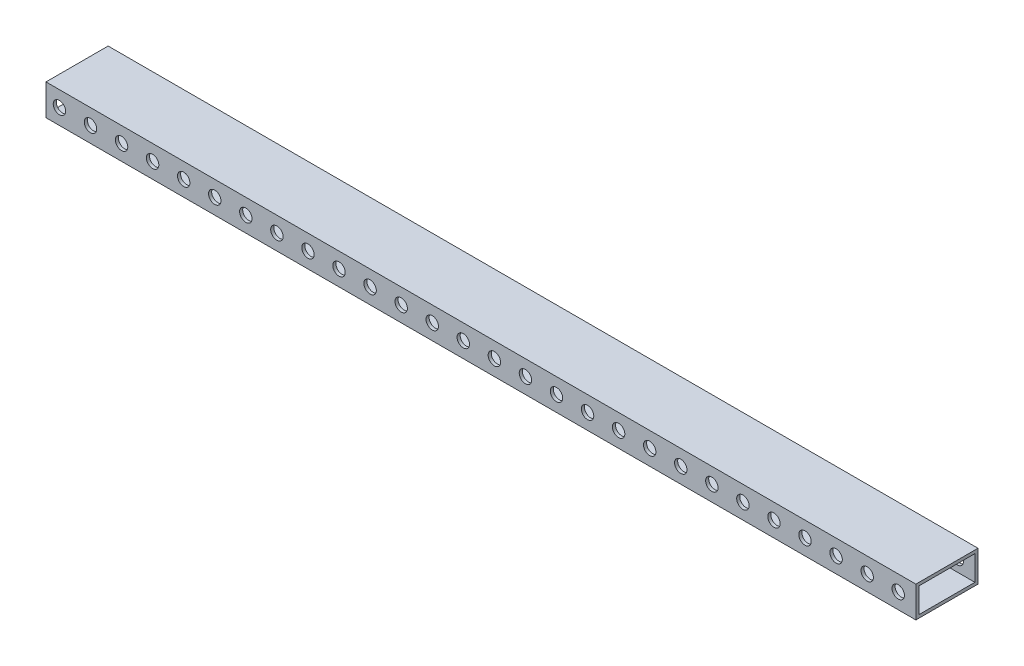
from build123d import *

# Parameters (mm, degrees)
SKETCH3_W           = 50.8
SKETCH3_H           = 25.4
SKETCH3_W_2         = 45.72
SKETCH3_H_2         = 20.32
BOSS_EXTRUDE1_DEPTH = 711.2
SKETCH5_R           = 5.08
CUT_EXTRUDE2_DEPTH  = 127


with BuildPart() as part:
    # Sketch3 → Boss-Extrude1 (new body)
    with BuildSketch(Plane(origin=(0, 0, 0), x_dir=(0, 0, -1), z_dir=(1, 0, 0))):
        with Locations((5.321216632, -1.999606833)):
            Rectangle(SKETCH3_W, SKETCH3_H)
        with Locations((5.321216632, -1.999606833)):
            Rectangle(SKETCH3_W_2, SKETCH3_H_2, mode=Mode.SUBTRACT)
    extrude(amount=BOSS_EXTRUDE1_DEPTH)

    # Sketch5 → Cut-Extrude2 (cut)
    with BuildSketch(Plane.XY.offset(20.078783368)):
        with Locations((10.978833808, -1.999606833)):
            Circle(SKETCH5_R)
        with Locations((36.378833808, -1.999606833)):
            Circle(SKETCH5_R)
        with Locations((61.778833808, -1.999606833)):
            Circle(SKETCH5_R)
        with Locations((87.178833808, -1.999606833)):
            Circle(SKETCH5_R)
        with Locations((112.578833808, -1.999606833)):
            Circle(SKETCH5_R)
        with Locations((137.978833808, -1.999606833)):
            Circle(SKETCH5_R)
        with Locations((163.378833808, -1.999606833)):
            Circle(SKETCH5_R)
        with Locations((188.778833808, -1.999606833)):
            Circle(SKETCH5_R)
        with Locations((214.178833808, -1.999606833)):
            Circle(SKETCH5_R)
        with Locations((239.578833808, -1.999606833)):
            Circle(SKETCH5_R)
        with Locations((264.978833808, -1.999606833)):
            Circle(SKETCH5_R)
        with Locations((290.378833808, -1.999606833)):
            Circle(SKETCH5_R)
        with Locations((315.778833808, -1.999606833)):
            Circle(SKETCH5_R)
        with Locations((341.178833808, -1.999606833)):
            Circle(SKETCH5_R)
        with Locations((366.578833808, -1.999606833)):
            Circle(SKETCH5_R)
        with Locations((391.978833808, -1.999606833)):
            Circle(SKETCH5_R)
        with Locations((417.378833808, -1.999606833)):
            Circle(SKETCH5_R)
        with Locations((442.778833808, -1.999606833)):
            Circle(SKETCH5_R)
        with Locations((468.178833808, -1.999606833)):
            Circle(SKETCH5_R)
        with Locations((493.578833808, -1.999606833)):
            Circle(SKETCH5_R)
        with Locations((518.978833808, -1.999606833)):
            Circle(SKETCH5_R)
        with Locations((544.378833808, -1.999606833)):
            Circle(SKETCH5_R)
        with Locations((569.778833808, -1.999606833)):
            Circle(SKETCH5_R)
        with Locations((595.178833808, -1.999606833)):
            Circle(SKETCH5_R)
        with Locations((620.578833808, -1.999606833)):
            Circle(SKETCH5_R)
        with Locations((645.978833808, -1.999606833)):
            Circle(SKETCH5_R)
        with Locations((671.378833808, -1.999606833)):
            Circle(SKETCH5_R)
        with Locations((696.778833808, -1.999606833)):
            Circle(SKETCH5_R)
    extrude(amount=-CUT_EXTRUDE2_DEPTH, mode=Mode.SUBTRACT)


solid = part.part
